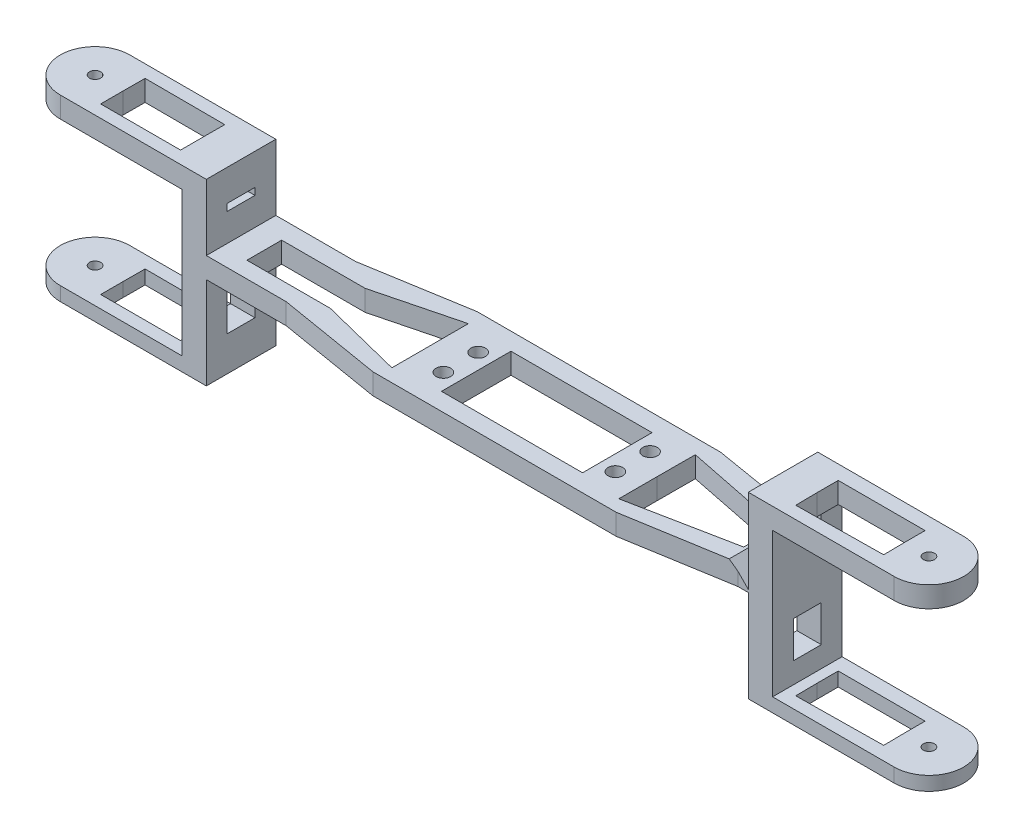
from build123d import *

# Parameters (mm, degrees)
SKETCH_1_W                = 70
SKETCH_1_H                = 30
SKETCH_1_W_2              = 40.6
SKETCH_1_H_2              = 20
EXTRUDE_1_DEPTH           = 51.5
SKETCH_2_R                = 2.1
CUT_EXTRUDE_1_DEPTH       = 52.5
SKETCH_3_R                = 1.6
EXTRUDE_2_DEPTH           = 51.5
SKETCH_17_W               = 155.974555081
SKETCH_17_H               = 17
SKETCH_17_H_2             = 26.5
CUT_EXTRUDE_8_DEPTH       = 31
CUT_EXTRUDE_9_DEPTH       = 52.5
SKETCH_20_W               = 8
SKETCH_20_H               = 10.5
SKETCH_20_H_2             = 2
CUT_EXTRUDE_10_DEPTH      = 208.974555081
CUT_EXTRUDE_10_DEPTH_BACK = 53.025444919
CUT_EXTRUDE_11_DEPTH      = 31


with BuildPart() as part:
    # 草图1 → 凸台-拉伸1 (new body)
    with BuildSketch(Plane(origin=(0, 0, 0), x_dir=(1, 0, 0), z_dir=(0, 1, 0))):
        with Locations((-7.06, 0.32447662)):
            Rectangle(SKETCH_1_W, SKETCH_1_H)
        with Locations((-7.06, 0.32447662)):
            Rectangle(SKETCH_1_W_2, SKETCH_1_H_2, mode=Mode.SUBTRACT)
    extrude(amount=EXTRUDE_1_DEPTH)

    # 草图2 → 切除-拉伸1 (cut, through all)
    with BuildSketch(Plane(origin=(0, 51.5, 0), x_dir=(1, 0, 0), z_dir=(0, 1, 0))):
        with Locations((-31.81, 5.32447662)):
            Circle(SKETCH_2_R)
        with Locations((-31.81, -4.67552338)):
            Circle(SKETCH_2_R)
        with Locations((17.69, -4.67552338)):
            Circle(SKETCH_2_R)
        with Locations((17.69, 5.32447662)):
            Circle(SKETCH_2_R)
    extrude(amount=-CUT_EXTRUDE_1_DEPTH, mode=Mode.SUBTRACT)

    # 草图3 → 凸台-拉伸2 (add)
    with BuildSketch(Plane(origin=(0, 51.5, 0), x_dir=(1, 0, 0), z_dir=(0, 1, 0))):
        with BuildLine():
            Line((-137.06, 10.32447662), (-72.06, 10.32447662))
            Line((-72.06, 10.32447662), (-42.06, 15.32447662))
            Line((-42.06, 15.32447662), (-42.06, -14.67552338))
            Line((-42.06, -14.67552338), (-72.06, -9.67552338))
            Line((-72.06, -9.67552338), (-137.06, -9.67552338))
            ThreePointArc((-137.06, -9.67552338), (-147.06, 0.32447662), (-137.06, 10.32447662))
        make_face()
        with Locations((-137.06, 0.32447662)):
            Circle(SKETCH_3_R, mode=Mode.SUBTRACT)
        with BuildLine():
            Line((57.94, 10.32447662), (102.94, 10.32447662))
            ThreePointArc((102.94, 10.32447662), (112.94, 0.32447662), (102.94, -9.67552338))
            Line((102.94, -9.67552338), (57.94, -9.67552338))
            Line((57.94, -9.67552338), (27.94, -14.67552338))
            Line((27.94, -14.67552338), (27.94, 15.32447662))
            Line((27.94, 15.32447662), (57.94, 10.32447662))
        make_face()
        with Locations((102.94, 0.32447662)):
            Circle(SKETCH_3_R, mode=Mode.SUBTRACT)
    extrude(amount=-EXTRUDE_2_DEPTH)

    # 草图17 → 切除-拉伸8 (cut, through all)
    with BuildSketch(Plane.XY.offset(14.67552338)):
        Polygon((112.94, 45.5), (67.94, 45.5), (67.94, 4), (112.94, 4), (117.101410497, 4), (117.101410497, 45.5), align=None)
        Polygon((-147.034555081, 45.5), (-117.034555081, 45.5), (-102.06, 45.5), (-102.06, 25.5), (-102.06, 4), (-117.034555081, 4), (-147.06, 4), (-149.583075769, 4), (-149.583075769, 45.5), align=None)
        with Locations((-17.047277541, 43)):
            Rectangle(SKETCH_17_W, SKETCH_17_H)
        with Locations((-17.047277541, 13.25)):
            Rectangle(SKETCH_17_W, SKETCH_17_H_2)
    extrude(amount=-CUT_EXTRUDE_8_DEPTH, mode=Mode.SUBTRACT)

    # 草图18 → 切除-拉伸9 (cut, through all)
    with BuildSketch(Plane.XZ):
        Polygon((70.94, -6.21374951), (70.94, -0.06239935), (71.016765061, 6.088471801), (96.014818298, 5.776487199), (95.94, -0.218397725), (95.94, -6.21374951), align=None)
        Polygon((-64.034555081, 4.990640098), (-88.034555081, 4.990640098), (-88.034555081, -5.009335567), (-64.034555081, -5.009335567), (-40.36, -11.056105877), (-40.36, 10.943840585), align=None)
        Polygon((54.94, -0.009359902), (54.94, 4.990640098), (24.94, 10.943840585), (24.94, -0.056159415), (24.974319559, -11.056105877), (54.9555998, -5.009335567), align=None)
        Polygon((-106.034555081, 6.088471801), (-106.034555081, -0.260477592), (-106.014746613, -6.609396085), (-129.01463467, -6.681155163), (-129.034555081, -0.296357219), (-129.034555081, 6.088471801), align=None)
    extrude(amount=-CUT_EXTRUDE_9_DEPTH, mode=Mode.SUBTRACT)

    # 草图20 → 切除-拉伸10 (cut, two sides)
    with BuildSketch(Plane(origin=(-95.034555081, 0, 0), x_dir=(0, 0, -1), z_dir=(1, 0, 0))) as cut_extrude_10_sk:
        with Locations((0.32447662, 15.25)):
            Rectangle(SKETCH_20_W, SKETCH_20_H)
        with Locations((0.32447662, 41.5)):
            Rectangle(SKETCH_20_W, SKETCH_20_H_2)
    extrude(amount=CUT_EXTRUDE_10_DEPTH, mode=Mode.SUBTRACT)
    extrude(cut_extrude_10_sk.sketch, amount=-CUT_EXTRUDE_10_DEPTH_BACK, mode=Mode.SUBTRACT)

    # 草图21 → 切除-拉伸11 (cut, through all)
    with BuildSketch(Plane(origin=(0, 0, -15.32447662), x_dir=(-1, 0, 0), z_dir=(0, 0, -1))):
        Polygon((-55.803056083, 32.5), (94.924677091, 32.5), (95.034555081, 32.5), (95.034555081, 34.5), (88.034555081, 34.5), (-60.94, 34.5), (-60.94, 27.3), align=None)
    extrude(amount=-CUT_EXTRUDE_11_DEPTH, mode=Mode.SUBTRACT)


solid = part.part
